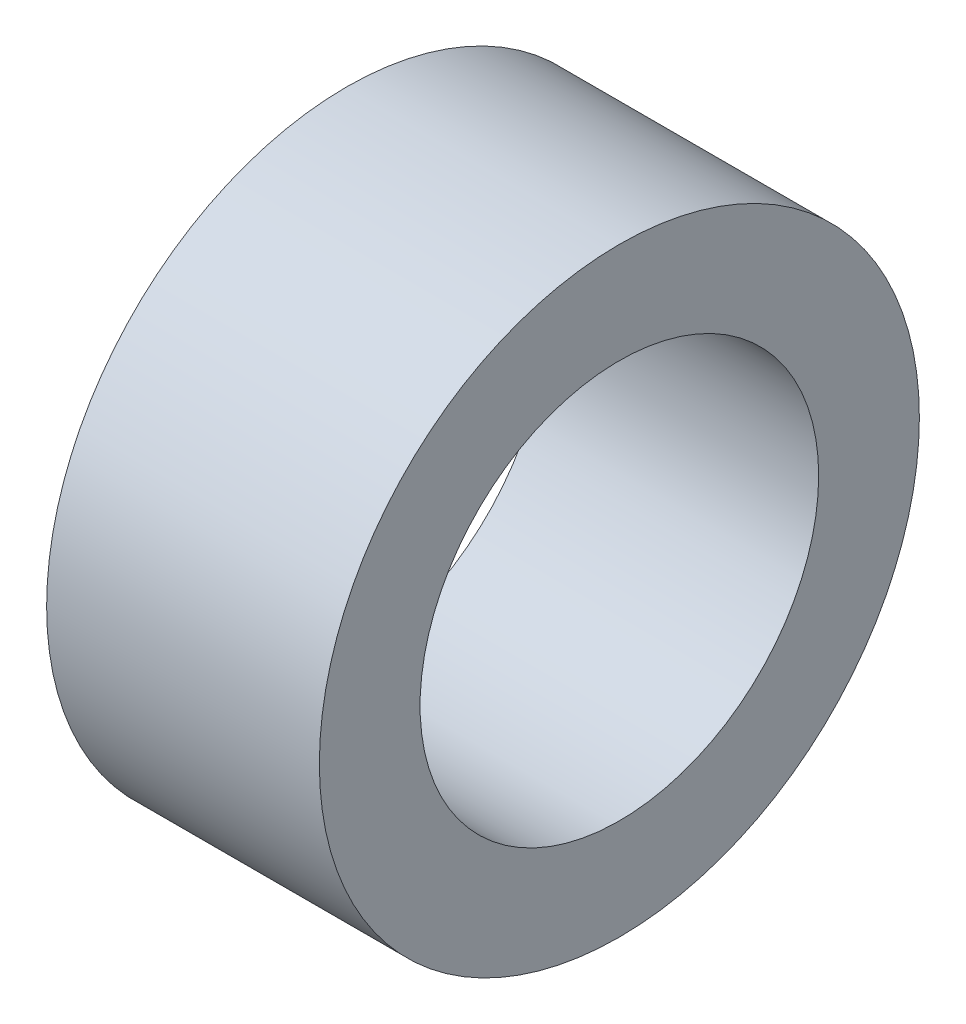
from build123d import *

# Parameters (mm, degrees)
ESQUISSE1_W             = 13
ESQUISSE1_H             = 14.3
ESQUISSE2_R             = 9.5
ENL_V_MAT_EXTRU_1_DEPTH = 14


with BuildPart() as part:
    # Esquisse1 → Révolution1 (revolve)
    with BuildSketch(Plane.XY):
        with Locations((6.5, 7.15)):
            Rectangle(ESQUISSE1_W, ESQUISSE1_H)
    revolve(axis=Axis((-11.341386336, 0, 0), (1, 0, 0)))

    # Esquisse2 → Enlèv. mat.-Extru.1 (cut, through all)
    with BuildSketch(Plane(origin=(13, 0, 0), x_dir=(0, 0, -1), z_dir=(1, 0, 0))):
        Circle(ESQUISSE2_R)
    extrude(amount=-ENL_V_MAT_EXTRU_1_DEPTH, mode=Mode.SUBTRACT)


solid = part.part
